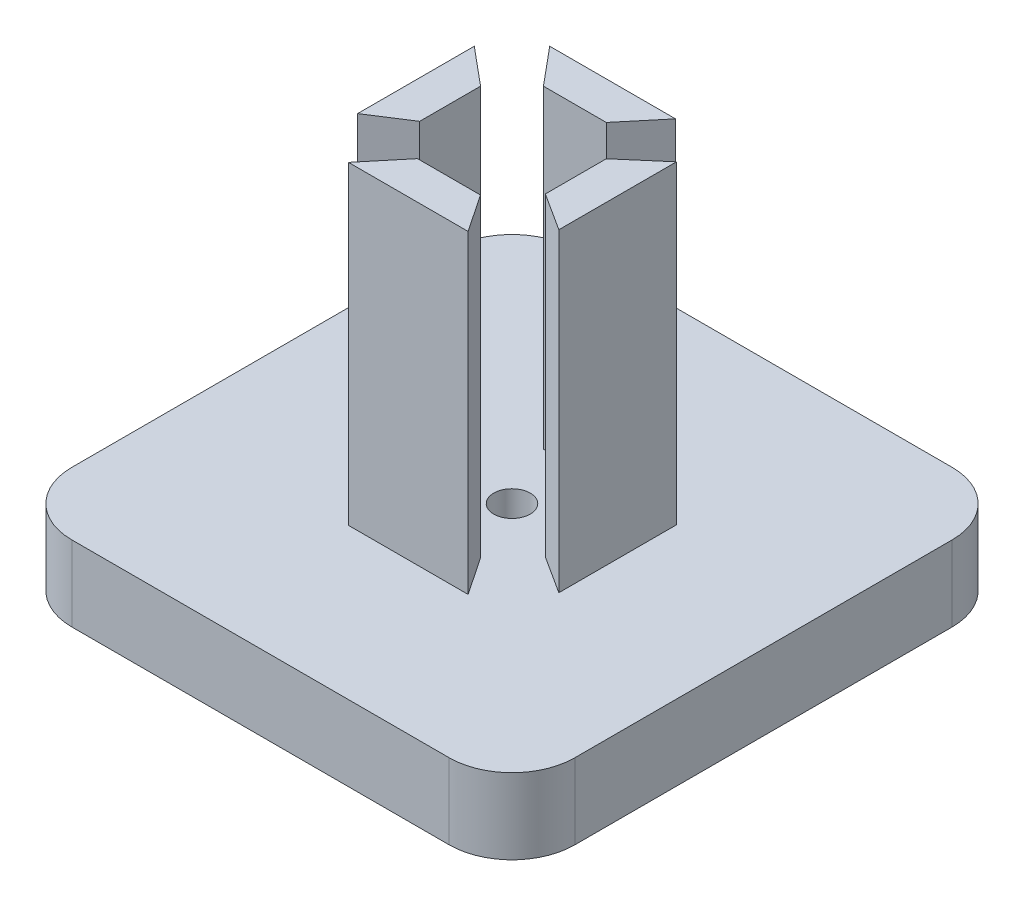
from build123d import *

# Parameters (mm, degrees)
SKETCH1_W           = 40
SKETCH1_H           = 40
BOSS_EXTRUDE1_DEPTH = 6
BOSS_EXTRUDE2_DEPTH = 25
BOSS_EXTRUDE3_DEPTH = 25
BOSS_EXTRUDE4_DEPTH = 25
CUT_EXTRUDE1_REACH  = 8
SKETCH6_R           = 1.45
FILLET1_R           = 5


with BuildPart() as part:
    # Sketch1 → Boss-Extrude1 (new body)
    with BuildSketch(Plane(origin=(0, 0, 0), x_dir=(1, 0, 0), z_dir=(0, 1, 0))):
        Rectangle(SKETCH1_W, SKETCH1_H)
    extrude(amount=BOSS_EXTRUDE1_DEPTH)

    # Sketch2 → Boss-Extrude2 (add)
    with BuildSketch(Plane(origin=(0, 6, 0), x_dir=(1, 0, 0), z_dir=(0, 1, 0))):
        Polygon((5, 8), (-5, 8), (-2.5, 5), (2.5, 5), align=None)
    extrude(amount=BOSS_EXTRUDE2_DEPTH)

    # Sketch4 → Boss-Extrude3 (add)
    with BuildSketch(Plane(origin=(0, 6, 0), x_dir=(1, 0, 0), z_dir=(0, 1, 0))):
        Polygon((-5, -8), (4.514189834, -8), (2.484709767, -5), (-2.515290233, -5), align=None)
    extrude(amount=BOSS_EXTRUDE3_DEPTH)

    # Sketch5 → Boss-Extrude4 (add)
    with BuildSketch(Plane(origin=(0, 6, 0), x_dir=(1, 0, 0), z_dir=(0, 1, 0))):
        Polygon((8, -4.275229645), (8, 5.076407548), (5, 2.5), (5, -2.347184903), align=None)
        Polygon((-8, -4.275229645), (-8, 5), (-5, 2.5), (-5, -2.347184903), align=None)
    extrude(amount=BOSS_EXTRUDE4_DEPTH)

    # Sketch6 → Cut-Extrude1 (cut, up to next)
    with BuildSketch(Plane(origin=(0, 6, 0), x_dir=(1, 0, 0), z_dir=(0, 1, 0)), mode=Mode.PRIVATE) as cut_extrude1_sk1:
        Circle(SKETCH6_R)
    cut_extrude1_tool1 = extrude(cut_extrude1_sk1.sketch, amount=-CUT_EXTRUDE1_REACH, mode=Mode.PRIVATE) & part.part
    add(cut_extrude1_tool1.solids().sort_by_distance((0, 6, 0))[0], mode=Mode.SUBTRACT)

    # Fillet1
    fillet1_edges = [part.edges().sort_by_distance(p)[0] for p in [
        (-20, 3, -20),
        (20, 3, -20),
        (20, 3, 20),
        (-20, 3, 20),
    ]]
    fillet(fillet1_edges, radius=FILLET1_R)


solid = part.part
